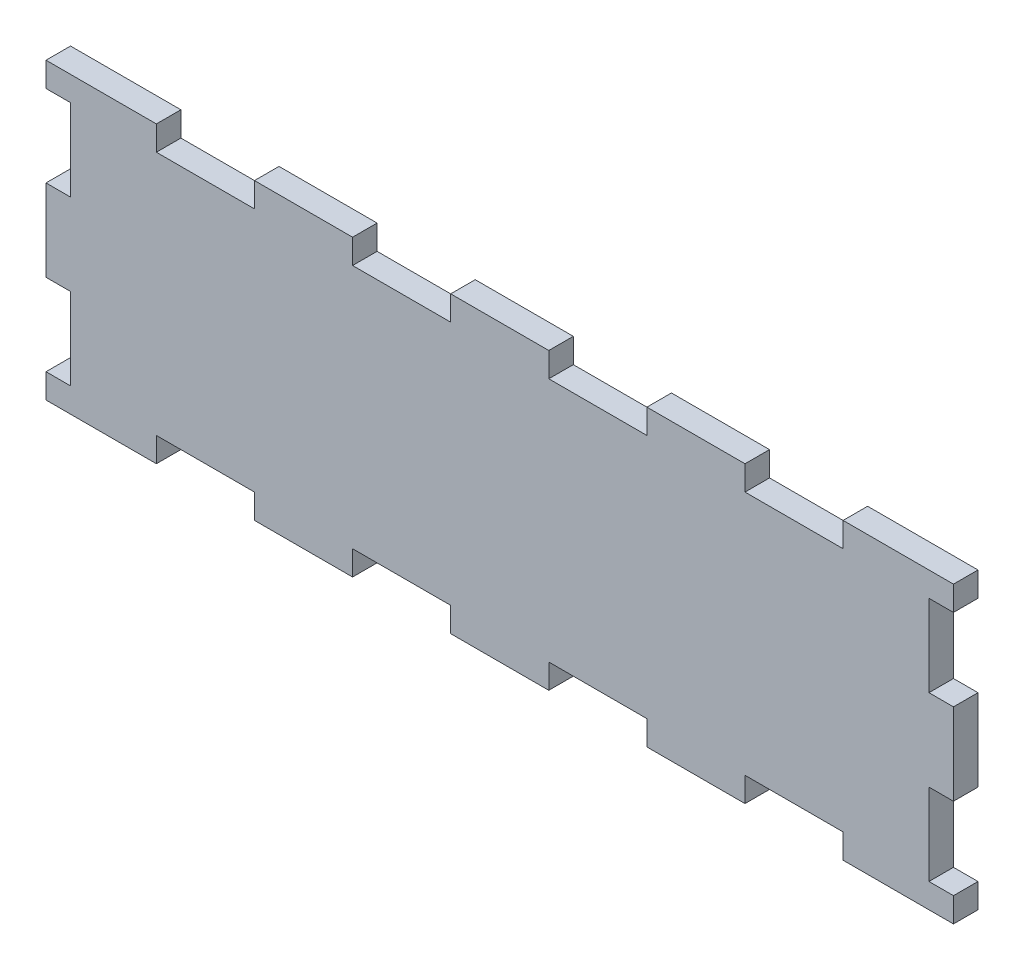
from build123d import *

# Parameters (mm, degrees)
BOSS_EXTRUDE1_DEPTH = 6


with BuildPart() as part:
    # Sketch1 → Boss-Extrude1 (new body)
    with BuildSketch(Plane.XY):
        Polygon((-84, 0), (-111, 0), (-111, 6), (-105, 6), (-105, 26), (-111, 26), (-111, 46), (-105, 46), (-105, 66), (-111, 66), (-111, 72), (-84, 72), (-84, 66), (-60, 66), (-60, 72), (-36, 72), (-36, 66), (-12, 66), (-12, 72), (12, 72), (12, 66), (36, 66), (36, 72), (60, 72), (60, 66), (84, 66), (84, 72), (111, 72), (111, 66), (105, 66), (105, 46), (111, 46), (111, 26), (105, 26), (105, 6), (111, 6), (111, 0), (84, 0), (84, 6), (60, 6), (60, 0), (36, 0), (36, 6), (12, 6), (12, 0), (-12, 0), (-12, 6), (-36, 6), (-36, 0), (-60, 0), (-60, 6), (-84, 6), align=None)
    extrude(amount=BOSS_EXTRUDE1_DEPTH)


solid = part.part
